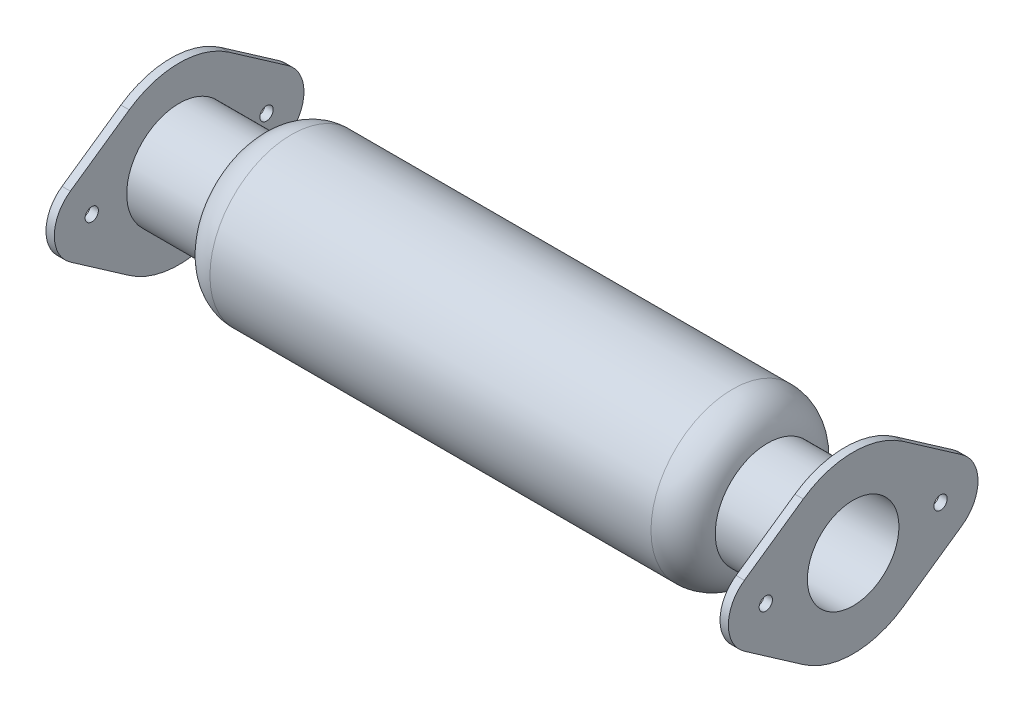
from build123d import *

# Parameters (mm, degrees)
SKETCH2_R           = 27.5
SKETCH2_R_2         = 4
BOSS_EXTRUDE1_DEPTH = 5


with BuildPart() as part:
    # Sketch1 → Revolve1 (revolve)
    with BuildSketch(Plane(origin=(0, 0, 0), x_dir=(1, 0, 0), z_dir=(0, 1, 0))):
        with BuildLine():
            Line((-200, 27.5), (-150, 27.5))
            ThreePointArc((-150, 27.5), (-144.874368671, 39.874368671), (-132.5, 45))
            Line((-132.5, 45), (132.5, 45))
            ThreePointArc((132.5, 45), (144.874368671, 39.874368671), (150, 27.5))
            Line((150, 27.5), (200, 27.5))
            Line((200, 27.5), (200, 31.5))
            Line((200, 31.5), (153.624630174, 31.5))
            ThreePointArc((153.624630174, 31.5), (146.215866724, 44.05672069), (132.5, 49))
            Line((132.5, 49), (-132.5, 49))
            ThreePointArc((-132.5, 49), (-146.215866724, 44.05672069), (-153.624630174, 31.5))
            Line((-153.624630174, 31.5), (-200, 31.5))
            Line((-200, 31.5), (-200, 27.5))
        make_face()
    revolve(axis=Axis((0, 0, 0), (-1, 0, 0)))

    # Sketch2 → Boss-Extrude1 (add)
    with BuildSketch(Plane.ZY.offset(200)):
        with BuildLine():
            Line((-30, 43.084219849), (-65.357142857, 18.46466565))
            ThreePointArc((-65.357142857, 18.46466565), (-75, 0), (-65.357142857, -18.46466565))
            Line((-65.357142857, -18.46466565), (-30, -43.084219849))
            ThreePointArc((-30, -43.084219849), (0, -52.5), (30, -43.084219849))
            Line((30, -43.084219849), (65.357142857, -18.46466565))
            ThreePointArc((65.357142857, -18.46466565), (75, 0), (65.357142857, 18.46466565))
            Line((65.357142857, 18.46466565), (30, 43.084219849))
            ThreePointArc((30, 43.084219849), (0, 52.5), (-30, 43.084219849))
        make_face()
        Circle(SKETCH2_R, mode=Mode.SUBTRACT)
        with Locations((-52.5, 0)):
            Circle(SKETCH2_R_2, mode=Mode.SUBTRACT)
        with Locations((52.5, 0)):
            Circle(SKETCH2_R_2, mode=Mode.SUBTRACT)
    boss_extrude1 = extrude(amount=BOSS_EXTRUDE1_DEPTH)

    # Mirror1: Boss-Extrude1 across plane
    add(boss_extrude1.mirror(Plane(origin=(0, 0, 0), x_dir=(0, 0, 1), z_dir=(1, 0, 0))))


solid = part.part
